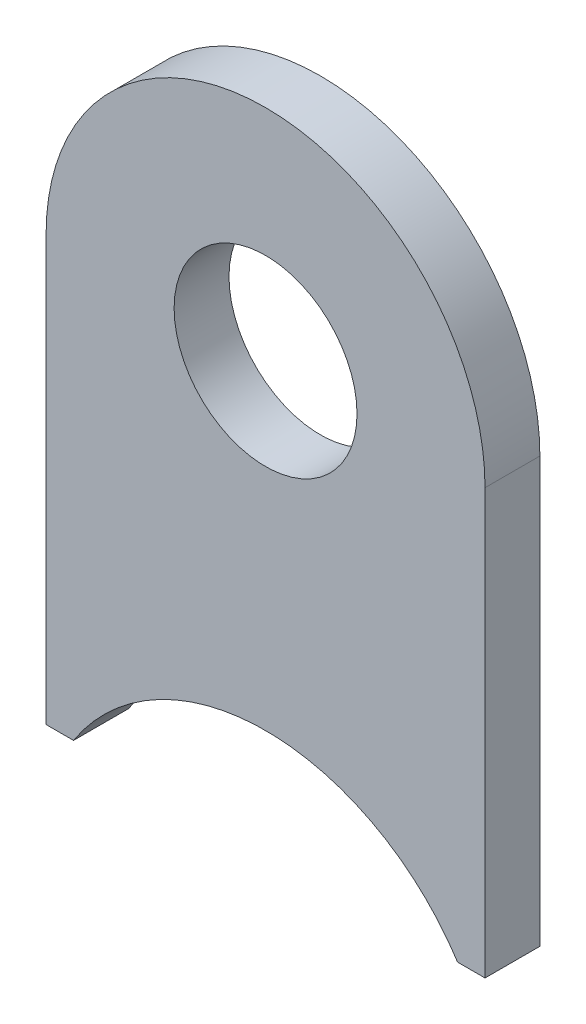
from build123d import *

# Parameters (mm, degrees)
SZKIC1_R                    = 5
DODANIE_WYCI_GNI_CIE1_DEPTH = 3


with BuildPart() as part:
    # Szkic1 → Dodanie-wyciągnięcie1 (new body)
    with BuildSketch(Plane(origin=(0, 0, -1.5), x_dir=(-1, 0, 0), z_dir=(0, 0, -1))):
        with BuildLine():
            Line((-12, 0), (-12, -23.217670017))
            Line((-12, -23.217670017), (-10.5, -23.217670017))
            ThreePointArc((-10.5, -23.217670017), (0, -17.5), (10.5, -23.217670017))
            Line((10.5, -23.217670017), (12, -23.217670017))
            Line((12, -23.217670017), (12, 0))
            ThreePointArc((12, 0), (0, 12), (-12, 0))
        make_face()
        Circle(SZKIC1_R, mode=Mode.SUBTRACT)
    extrude(amount=-DODANIE_WYCI_GNI_CIE1_DEPTH)


solid = part.part
